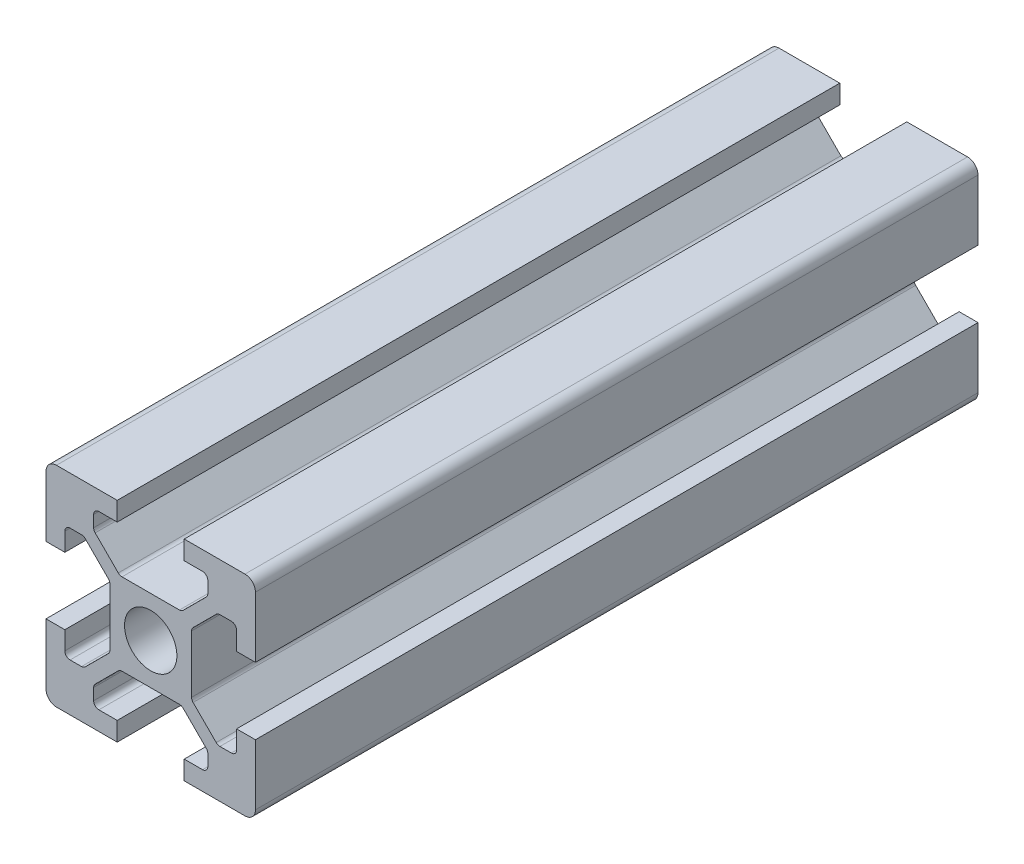
from build123d import *

# Parameters (mm, degrees)
SKETCH1_R           = 2.5
BOSS_EXTRUDE1_DEPTH = 69
FILLET1_R           = 1
FILLET2_R           = 0.5
FILLET3_R           = 0.5
FILLET4_R           = 0.5
FILLET5_R           = 0.5


with BuildPart() as part:
    # Sketch1 → Boss-Extrude1 (new body)
    with BuildSketch(Plane.XY):
        Polygon((13.2, 0), (13.2, 1.8), (15.45, 1.8), (15.45, 3.6), (12.95, 6.1), (7.05, 6.1), (4.55, 3.6), (4.55, 1.8), (6.8, 1.8), (6.8, 0), (0, 0), (0, 6.8), (1.8, 6.8), (1.8, 4.55), (3.6, 4.55), (6.1, 7.05), (6.1, 12.95), (3.6, 15.45), (1.8, 15.45), (1.8, 13.2), (0, 13.2), (0, 20), (6.8, 20), (6.8, 18.2), (4.55, 18.2), (4.55, 16.4), (7.05, 13.9), (12.95, 13.9), (15.45, 16.4), (15.45, 18.2), (13.2, 18.2), (13.2, 20), (20, 20), (20, 13.2), (18.2, 13.2), (18.2, 15.45), (16.4, 15.45), (13.9, 12.95), (13.9, 7.05), (16.4, 4.55), (18.2, 4.55), (18.2, 6.8), (20, 6.8), (20, 0), align=None)
        with Locations((10, 10)):
            Circle(SKETCH1_R, mode=Mode.SUBTRACT)
    extrude(amount=BOSS_EXTRUDE1_DEPTH)

    # Fillet1
    fillet1_edges = [part.edges().sort_by_distance(p)[0] for p in [
        (0, 0, 34.5),
        (0, 20, 34.5),
        (20, 20, 34.5),
        (20, 0, 34.5),
    ]]
    fillet(fillet1_edges, radius=FILLET1_R)

    # Fillet2
    fillet2_edges = [part.edges().sort_by_distance(p)[0] for p in [
        (4.55, 18.2, 34.5),
        (4.55, 16.4, 34.5),
        (7.05, 13.9, 34.5),
        (12.95, 13.9, 34.5),
        (15.45, 16.4, 34.5),
        (15.45, 18.2, 34.5),
    ]]
    fillet(fillet2_edges, radius=FILLET2_R)

    # Fillet3
    fillet3_edges = [part.edges().sort_by_distance(p)[0] for p in [
        (18.2, 15.45, 34.5),
        (16.4, 15.45, 34.5),
        (13.9, 12.95, 34.5),
        (13.9, 7.05, 34.5),
        (16.4, 4.55, 34.5),
        (18.2, 4.55, 34.5),
    ]]
    fillet(fillet3_edges, radius=FILLET3_R)

    # Fillet4
    fillet4_edges = [part.edges().sort_by_distance(p)[0] for p in [
        (1.8, 4.55, 34.5),
        (3.6, 4.55, 34.5),
        (6.1, 7.05, 34.5),
        (6.1, 12.95, 34.5),
        (3.6, 15.45, 34.5),
        (1.8, 15.45, 34.5),
    ]]
    fillet(fillet4_edges, radius=FILLET4_R)

    # Fillet5
    fillet5_edges = [part.edges().sort_by_distance(p)[0] for p in [
        (15.45, 1.8, 34.5),
        (15.45, 3.6, 34.5),
        (12.95, 6.1, 34.5),
        (7.05, 6.1, 34.5),
        (4.55, 3.6, 34.5),
        (4.55, 1.8, 34.5),
    ]]
    fillet(fillet5_edges, radius=FILLET5_R)


solid = part.part
